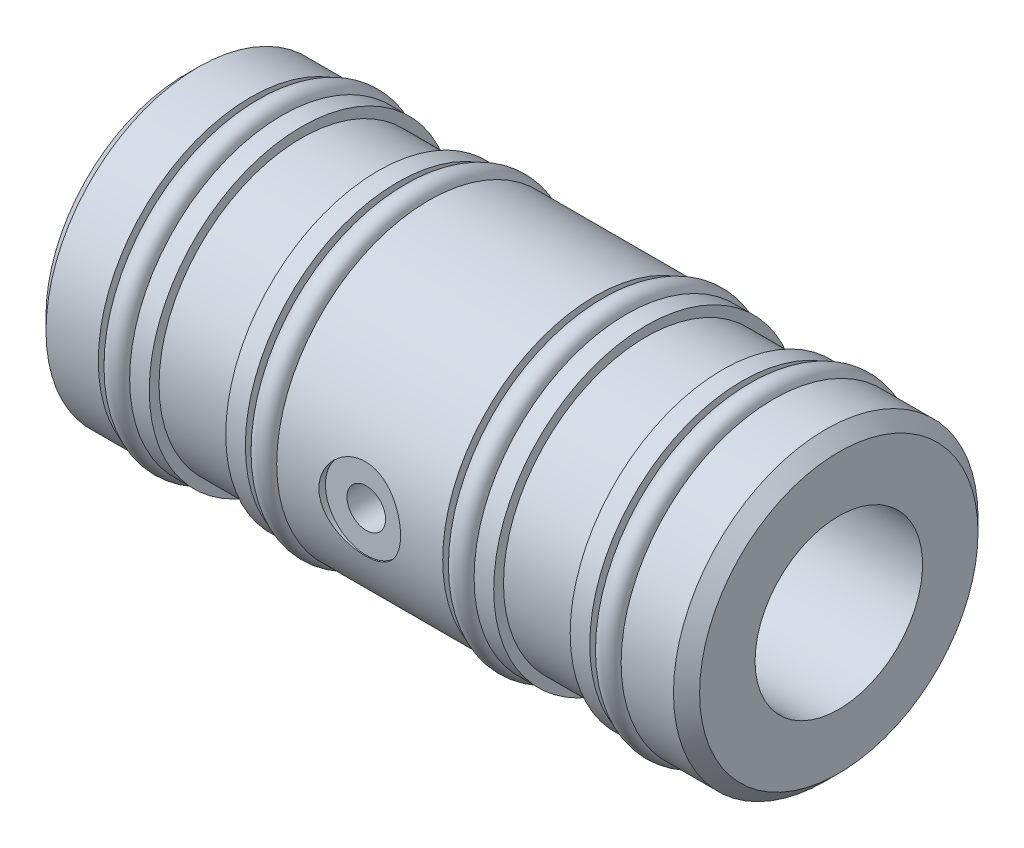
from build123d import *

# Parameters (mm, degrees)
CHAMFER1_SIZE                   = 1.016
F_1_4_0_25_DIAMETER_HOLE1_D     = 6.35
F_1_4_0_25_DIAMETER_HOLE1_DEPTH = 0.51
AIR_HOLE_D                      = 2.4892
AIR_HOLE_DEPTH                  = 6.35
AIR_HOLE_CBORE_D                = 3
AIR_HOLE_CBORE_DEPTH            = 5.99
AIR_HOLE_TIP                    = 0.747831126
SKETCH5_R                       = 0.8763


with BuildPart() as part:
    # Sketch1 → Revolve1 (revolve)
    with BuildSketch(Plane.XY, mode=Mode.PRIVATE) as revolve1_sk:
        Polygon((0, 6.51), (50.8, 6.51), (50.8, 11.835), (45.718, 11.835), (45.718, 10.615), (43.28, 10.615), (43.28, 11.835), (41.7576, 11.835), (41.7576, 11.075), (35.814, 11.075), (35.814, 11.835), (34.288, 11.835), (34.288, 10.615), (31.85, 10.615), (31.85, 11.835), (18.948, 11.835), (18.948, 10.615), (16.51, 10.615), (16.51, 11.835), (14.986, 11.835), (14.986, 11.075), (9.0424, 11.075), (9.0424, 11.835), (7.518, 11.835), (7.518, 10.615), (5.08, 10.615), (5.08, 11.835), (0, 11.835), align=None)
    revolve(revolve1_sk.sketch.rotate(Axis((0, 0, 0), (1, 0, 0)), 90), axis=Axis((0, 0, 0), (1, 0, 0)))  # turned: the seam where the file's is

    # Chamfer1
    chamfer1_edges = [part.edges().sort_by_distance(p)[0] for p in [
        (50.8, 0, -11.835),
        (0, 0, -11.835),
    ]]
    chamfer(chamfer1_edges, length=CHAMFER1_SIZE)

    # 1/4 (0.25) Diameter Hole1
    with Locations(Plane(origin=(25.4, 0, 11.835), x_dir=(1, 0, 0), z_dir=(0, 0, 1))):
        with Locations((0, 0)):
            Hole(F_1_4_0_25_DIAMETER_HOLE1_D / 2, depth=F_1_4_0_25_DIAMETER_HOLE1_DEPTH)

    # Air Hole
    with Locations(Plane.XY.offset(11.325)):
        with Locations((25.4, 0)):
            CounterBoreHole(AIR_HOLE_D / 2, AIR_HOLE_CBORE_D / 2, AIR_HOLE_CBORE_DEPTH, depth=AIR_HOLE_DEPTH)
            with Locations((0, 0, -(AIR_HOLE_DEPTH + AIR_HOLE_TIP / 2))):  # 118° drill point
                Cone(0, AIR_HOLE_D / 2, AIR_HOLE_TIP, mode=Mode.SUBTRACT)

    # Sketch5 → Revolve2 (revolve)
    with BuildSketch(Plane.XY, mode=Mode.PRIVATE) as revolve2_sk:
        with Locations((44.5, 11.3737)):
            Circle(SKETCH5_R)
        with Locations((33.07, 11.3737)):
            Circle(SKETCH5_R)
        with Locations((17.728, 11.3737)):
            Circle(SKETCH5_R)
        with Locations((6.2988, 11.3737)):
            Circle(SKETCH5_R)
    revolve(revolve2_sk.sketch.rotate(Axis((0, 0, 0), (1, 0, 0)), 90), axis=Axis((0, 0, 0), (1, 0, 0)))  # turned: the seam where the file's is


solid = part.part
